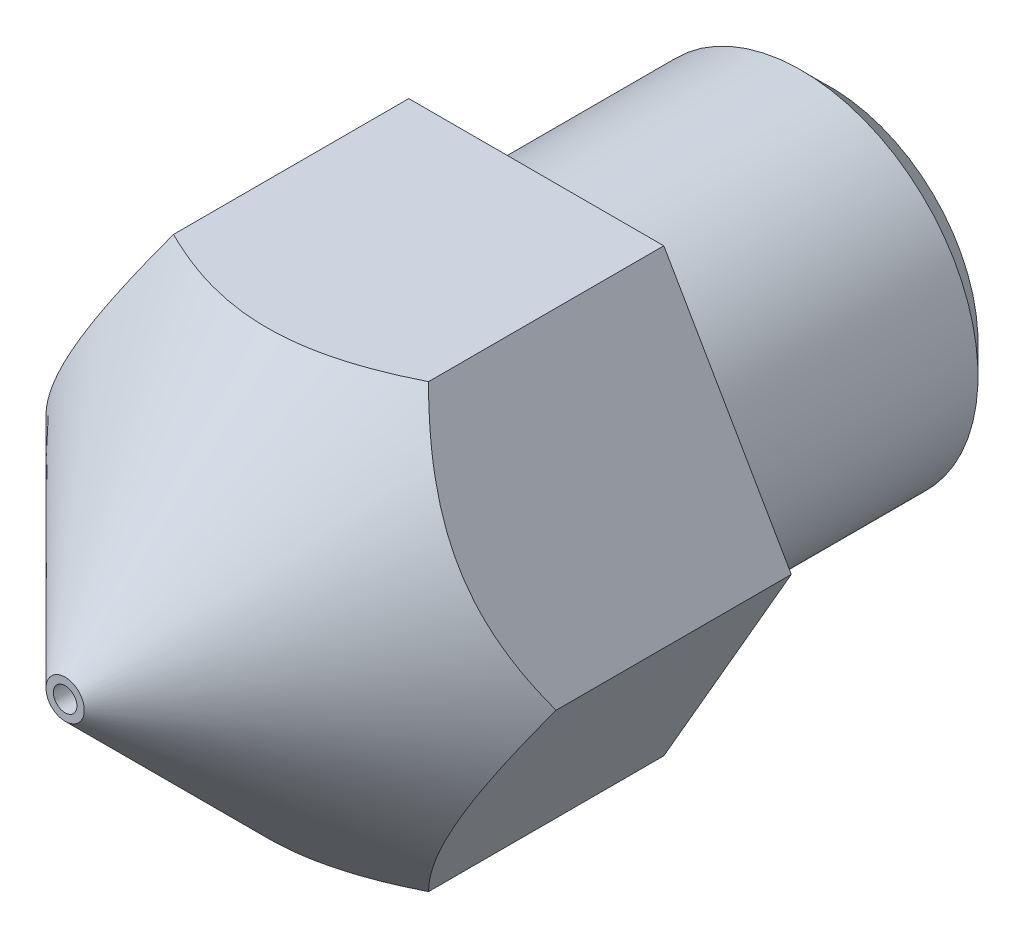
from build123d import *

# Parameters (mm, degrees)
SKETCH2_R          = 8.325
CUT_EXTRUDE2_DEPTH = 10
CHAMFER1_SIZE      = 0.5


with BuildPart() as part:
    # Sketch1 → Revolve1 (revolve)
    with BuildSketch(Plane(origin=(0, 0, 0), x_dir=(1, 0, 0), z_dir=(0, 1, 0))):
        Polygon((1.55, 0), (3, 0), (3, -5), (8.325, -5), (0.325, -13), (0.2, -13), (0.2, -12.5), (1, -10.9), (1, -10), (1, -1), (1.55, -1), align=None)
    revolve(axis=Axis((0, 0, 0), (0, 0, 1)))

    # Sketch2 → Cut-Extrude2 (cut)
    with BuildSketch(Plane(origin=(0, 0, 5), x_dir=(-1, 0, 0), z_dir=(0, 0, -1))):
        Circle(SKETCH2_R)
        Polygon((-4.330127019, 0), (-2.165063509, -3.75), (2.165063509, -3.75), (4.330127019, 0), (2.165063509, 3.75), (-2.165063509, 3.75), align=None, mode=Mode.SUBTRACT)
    extrude(amount=-CUT_EXTRUDE2_DEPTH, mode=Mode.SUBTRACT)

    # Chamfer1
    chamfer1_edges = [part.edges().sort_by_distance(p)[0] for p in [
        (-3, 0, 0),
    ]]
    chamfer(chamfer1_edges, length=CHAMFER1_SIZE)


solid = part.part
